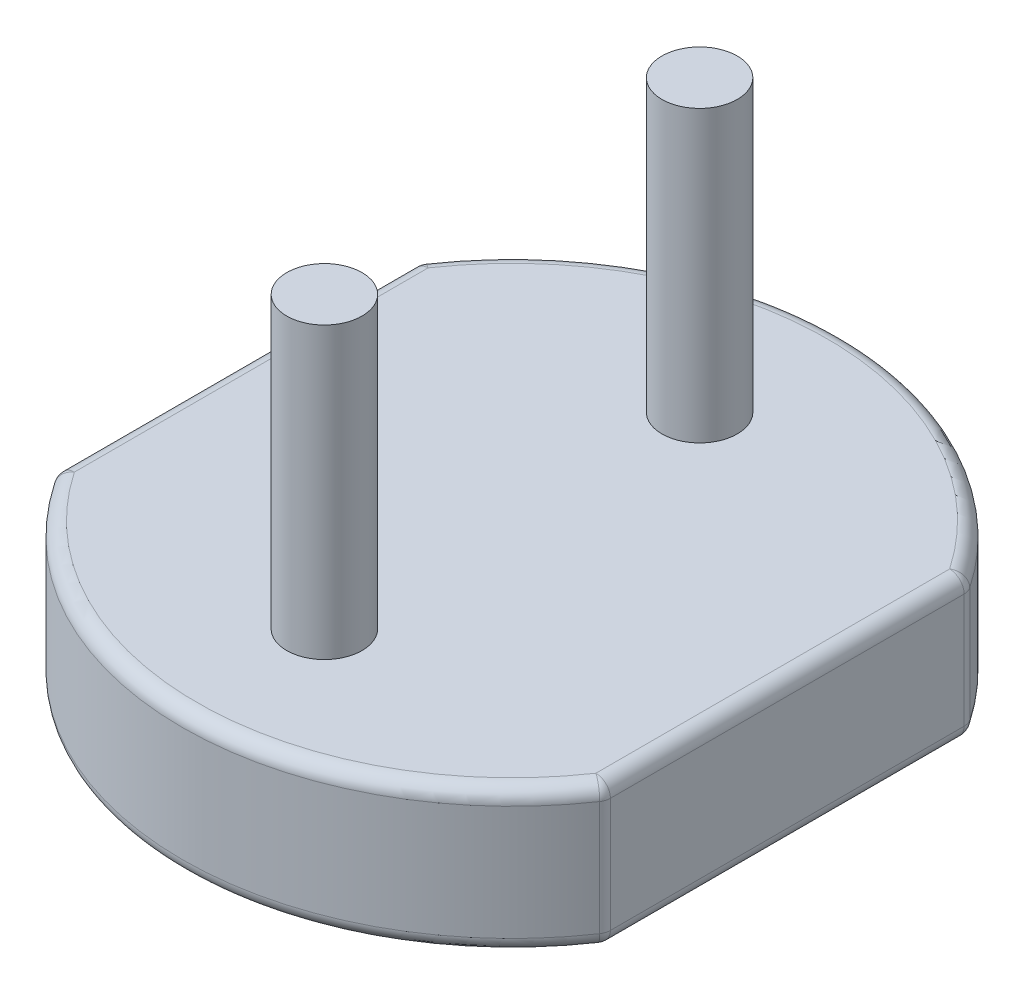
from build123d import *

# Parameters (mm, degrees)
BOSS_EXTRUDE1_DEPTH      = 1
SKETCH2_R                = 0.26
BOSS_EXTRUDE2_DEPTH      = 10
BOSS_EXTRUDE2_DEPTH_BACK = 1.1
CUT_EXTRUDE1_DEPTH       = 0.01
FILLET1_R                = 0.1
SCHIZZO1_R               = 0.26
TAGLIO_ESTRUSIONE1_DEPTH = 8


with BuildPart() as part:
    # Sketch1 → Boss-Extrude1 (new body)
    with BuildSketch(Plane(origin=(0, 0, 0), x_dir=(1, 0, 0), z_dir=(0, 1, 0))):
        with BuildLine():
            Line((-1.9, 1.251249376), (-1.9, -1.251249376))
            ThreePointArc((-1.9, -1.251249376), (0, -2.275), (1.9, -1.251249376))
            Line((1.9, -1.251249376), (1.9, 1.251249376))
            ThreePointArc((1.9, 1.251249376), (0, 2.275), (-1.9, 1.251249376))
        make_face()
    extrude(amount=BOSS_EXTRUDE1_DEPTH)

    # Sketch2 → Boss-Extrude2 (add, two sides)
    with BuildSketch(Plane(origin=(0, 1, 0), x_dir=(1, 0, 0), z_dir=(0, 1, 0))) as boss_extrude2_sk:
        with Locations((0, 1.295)):
            Circle(SKETCH2_R)
        with Locations((0, -1.295)):
            Circle(SKETCH2_R)
    extrude(amount=BOSS_EXTRUDE2_DEPTH)
    extrude(boss_extrude2_sk.sketch, amount=-BOSS_EXTRUDE2_DEPTH_BACK)

    # Sketch4 → Cut-Extrude1 (cut)
    with BuildSketch(Plane.XZ):
        with BuildLine():
            Line((1.9, -1.251249376), (1.9, 1.251249376))
            ThreePointArc((1.9, 1.251249376), (0, 2.275), (-1.9, 1.251249376))
            Line((-1.9, 1.251249376), (-1.9, -1.251249376))
            ThreePointArc((-1.9, -1.251249376), (0, -2.275), (1.9, -1.251249376))
        make_face()
        with BuildLine():
            Line((-1.4, 1.091157642), (-1.4, -1.091157642))
            ThreePointArc((-1.4, -1.091157642), (0, -1.775), (1.4, -1.091157642))
            Line((1.4, -1.091157642), (1.4, 1.091157642))
            ThreePointArc((1.4, 1.091157642), (1.375341403, 1.122078885), (1.35, 1.152443057))
            Line((1.35, 1.152443057), (1.35, -1))
            ThreePointArc((1.35, -1), (1.2, -1.15), (1.05, -1))
            Line((1.05, -1), (1.05, 0.9))
            ThreePointArc((1.05, 0.9), (0.9, 1.05), (0.75, 0.9))
            Line((0.75, 0.9), (0.75, -0.9))
            ThreePointArc((0.75, -0.9), (0.6, -1.05), (0.45, -0.9))
            Line((0.45, -0.9), (0.45, 0.7))
            ThreePointArc((0.45, 0.7), (0.3, 0.85), (0.15, 0.7))
            Line((0.15, 0.7), (0.15, -0.75))
            ThreePointArc((0.15, -0.75), (0, -0.9), (-0.15, -0.75))
            Line((-0.15, -0.75), (-0.15, 0.7))
            ThreePointArc((-0.15, 0.7), (-0.3, 0.85), (-0.45, 0.7))
            Line((-0.45, 0.7), (-0.45, -0.9))
            ThreePointArc((-0.45, -0.9), (-0.6, -1.05), (-0.75, -0.9))
            Line((-0.75, -0.9), (-0.75, 0.9))
            ThreePointArc((-0.75, 0.9), (-0.9, 1.05), (-1.05, 0.9))
            Line((-1.05, 0.9), (-1.05, -1))
            ThreePointArc((-1.05, -1), (-1.2, -1.15), (-1.35, -1))
            Line((-1.35, -1), (-1.35, 1.152443057))
            ThreePointArc((-1.35, 1.152443057), (-1.375341403, 1.122078885), (-1.4, 1.091157642))
        make_face(mode=Mode.SUBTRACT)
        with BuildLine():
            Line((1.25, 1.152443057), (1.25, -1))
            ThreePointArc((1.25, -1), (1.2, -1.05), (1.15, -1))
            Line((1.15, -1), (1.15, 0.9))
            ThreePointArc((1.15, 0.9), (0.9, 1.15), (0.65, 0.9))
            Line((0.65, 0.9), (0.65, -0.9))
            ThreePointArc((0.65, -0.9), (0.6, -0.95), (0.55, -0.9))
            Line((0.55, -0.9), (0.55, 0.7))
            ThreePointArc((0.55, 0.7), (0.3, 0.95), (0.05, 0.7))
            Line((0.05, 0.7), (0.05, -0.75))
            ThreePointArc((0.05, -0.75), (0.035355339, -0.785355339), (0, -0.8))
            ThreePointArc((0, -0.8), (-0.035355339, -0.785355339), (-0.05, -0.75))
            Line((-0.05, -0.75), (-0.05, 0.7))
            ThreePointArc((-0.05, 0.7), (-0.3, 0.95), (-0.55, 0.7))
            Line((-0.55, 0.7), (-0.55, -0.9))
            ThreePointArc((-0.55, -0.9), (-0.6, -0.95), (-0.65, -0.9))
            Line((-0.65, -0.9), (-0.65, 0.9))
            ThreePointArc((-0.65, 0.9), (-0.9, 1.15), (-1.15, 0.9))
            Line((-1.15, 0.9), (-1.15, -1))
            ThreePointArc((-1.15, -1), (-1.2, -1.05), (-1.25, -1))
            Line((-1.25, -1), (-1.25, 1.152443057))
            Line((-1.25, 1.152443057), (-1.25, 1.260208316))
            ThreePointArc((-1.25, 1.260208316), (0, 1.775), (1.25, 1.260208316))
            Line((1.25, 1.260208316), (1.25, 1.152443057))
        make_face(mode=Mode.SUBTRACT)
    extrude(amount=-CUT_EXTRUDE1_DEPTH, mode=Mode.SUBTRACT)

    # Fillet1
    fillet1_edges = [part.edges().sort_by_distance(p)[0] for p in [
        (0, 1, 2.275),
        (1.9, 1, 0),
        (0, 1, -2.275),
        (0, 0.01, -2.275),
        (-1.9, 0.01, 0),
        (0, 0.01, 2.275),
        (1.9, 0.01, 0),
        (-1.9, 1, 0),
        (1.9, 0.505, -1.251249376),
        (1.9, 0.505, 1.251249376),
        (-1.9, 0.505, 1.251249376),
        (-1.9, 0.505, -1.251249376),
    ]]
    fillet(fillet1_edges, radius=FILLET1_R)

    # Schizzo1 → Taglio-Estrusione1 (cut)
    with BuildSketch(Plane(origin=(0, 11, 0), x_dir=(1, 0, 0), z_dir=(0, 1, 0))):
        with Locations((0, 1.295)):
            Circle(SCHIZZO1_R)
        with Locations((0, -1.295)):
            Circle(SCHIZZO1_R)
    extrude(amount=-TAGLIO_ESTRUSIONE1_DEPTH, mode=Mode.SUBTRACT)


solid = part.part
